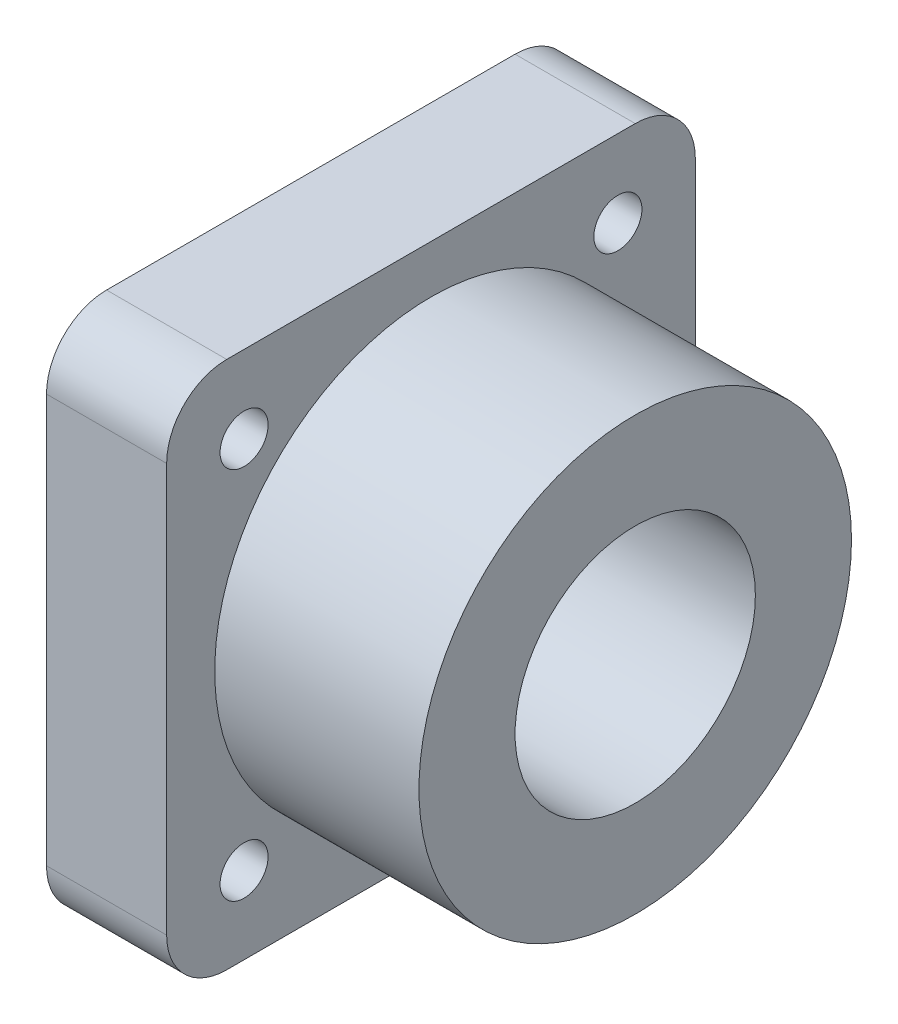
from build123d import *

# Parameters (mm, degrees)
SKETCH1_W           = 44
SKETCH1_H           = 44
SKETCH1_R           = 2
SKETCH1_R_2         = 10
BOSS_EXTRUDE1_DEPTH = 10
SKETCH2_R           = 18
SKETCH2_R_2         = 10
BOSS_EXTRUDE2_DEPTH = 27
FILLET1_R           = 5


with BuildPart() as part:
    # Sketch1 → Boss-Extrude1 (new body)
    with BuildSketch(Plane(origin=(0, 0, 0), x_dir=(0, 0, -1), z_dir=(1, 0, 0))):
        Rectangle(SKETCH1_W, SKETCH1_H)
        with Locations((-15.556349186, 15.556349186)):
            Circle(SKETCH1_R, mode=Mode.SUBTRACT)
        with Locations((15.556349186, 15.556349186)):
            Circle(SKETCH1_R, mode=Mode.SUBTRACT)
        with Locations((15.556349186, -15.556349186)):
            Circle(SKETCH1_R, mode=Mode.SUBTRACT)
        with Locations((-15.556349186, -15.556349186)):
            Circle(SKETCH1_R, mode=Mode.SUBTRACT)
        Circle(SKETCH1_R_2, mode=Mode.SUBTRACT)
    extrude(amount=BOSS_EXTRUDE1_DEPTH)

    # Sketch2 → Boss-Extrude2 (add)
    with BuildSketch(Plane(origin=(0, 0, 0), x_dir=(0, 0, -1), z_dir=(1, 0, 0))):
        Circle(SKETCH2_R)
        Circle(SKETCH2_R_2, mode=Mode.SUBTRACT)
    extrude(amount=BOSS_EXTRUDE2_DEPTH)

    # Fillet1
    fillet1_edges = [part.edges().sort_by_distance(p)[0] for p in [
        (5, 22, 22),
        (5, 22, -22),
        (5, -22, -22),
        (5, -22, 22),
    ]]
    fillet(fillet1_edges, radius=FILLET1_R)


solid = part.part
